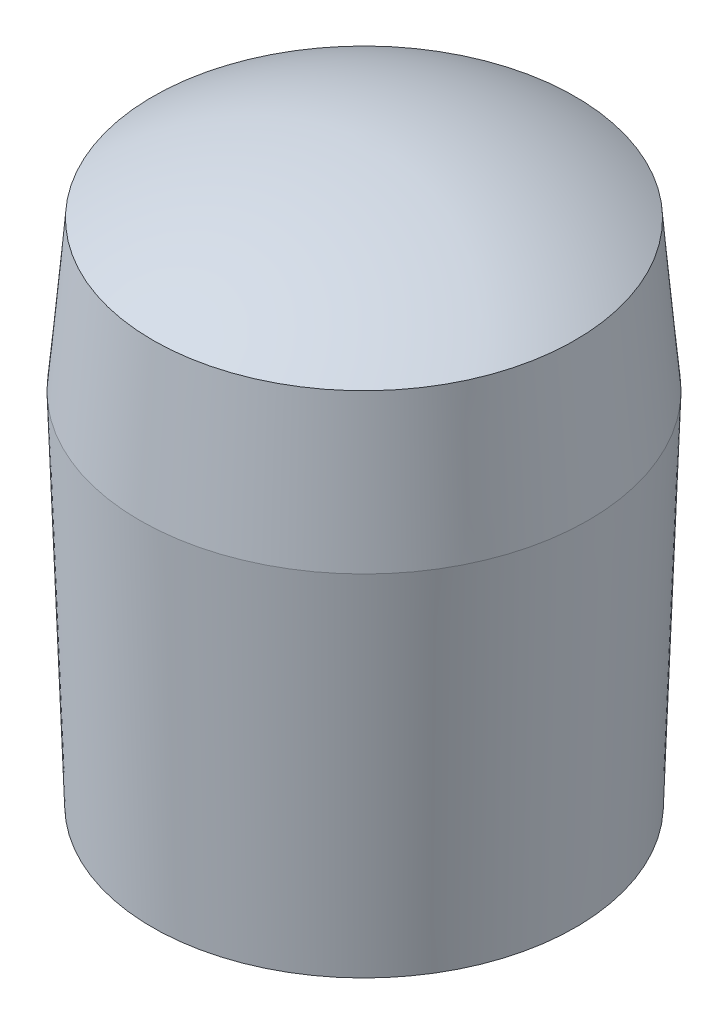
from build123d import *

# Parameters (mm, degrees)
SKETCH1_R           = 0.75
BOSS_EXTRUDE1_DEPTH = 0.5
BOSS_EXTRUDE1_TAPER = 5
DOME1_FACE_RADIUS   = 0.706255668
DOME1_HEIGHT        = 0.2
SKETCH2_R           = 0.75
BOSS_EXTRUDE2_DEPTH = 1.2
BOSS_EXTRUDE2_TAPER = 2
DOME3_FACE_RADIUS   = 0.708095077
DOME3_HEIGHT        = 0.2


with BuildPart() as part:
    # Sketch1 → Boss-Extrude1 (new body)
    with BuildSketch(Plane(origin=(0, 0, 0), x_dir=(1, 0, 0), z_dir=(0, 1, 0))):
        Circle(SKETCH1_R)
    extrude(amount=BOSS_EXTRUDE1_DEPTH, taper=BOSS_EXTRUDE1_TAPER)

    # Dome1: a dome of height H over a round flat face of radius A is a cap of a sphere of radius (A * A + H * H) / (2 * H)
    dome1_r = (DOME1_FACE_RADIUS * DOME1_FACE_RADIUS + DOME1_HEIGHT * DOME1_HEIGHT) / (2 * DOME1_HEIGHT)
    dome1_base = Plane((0, 0.5, 0), z_dir=(0, 1, 0))
    with Locations(dome1_base.offset(DOME1_HEIGHT - dome1_r)):
        dome1_ball = Sphere(dome1_r, mode=Mode.PRIVATE)
    add(split(dome1_ball, bisect_by=dome1_base, keep=Keep.TOP, mode=Mode.PRIVATE))

    # Sketch2 → Boss-Extrude2 (add)
    with BuildSketch(Plane.XZ):
        Circle(SKETCH2_R)
    extrude(amount=BOSS_EXTRUDE2_DEPTH, taper=BOSS_EXTRUDE2_TAPER)

    # Dome3: a dome of height H over a round flat face of radius A is a cap of a sphere of radius (A * A + H * H) / (2 * H)
    dome3_r = (DOME3_FACE_RADIUS * DOME3_FACE_RADIUS + DOME3_HEIGHT * DOME3_HEIGHT) / (2 * DOME3_HEIGHT)
    dome3_base = Plane((0, -1.2, 0), z_dir=(0, -1, 0))
    with Locations(dome3_base.offset(DOME3_HEIGHT - dome3_r)):
        dome3_ball = Sphere(dome3_r, mode=Mode.PRIVATE)
    add(split(dome3_ball, bisect_by=dome3_base, keep=Keep.TOP, mode=Mode.PRIVATE))


solid = part.part
